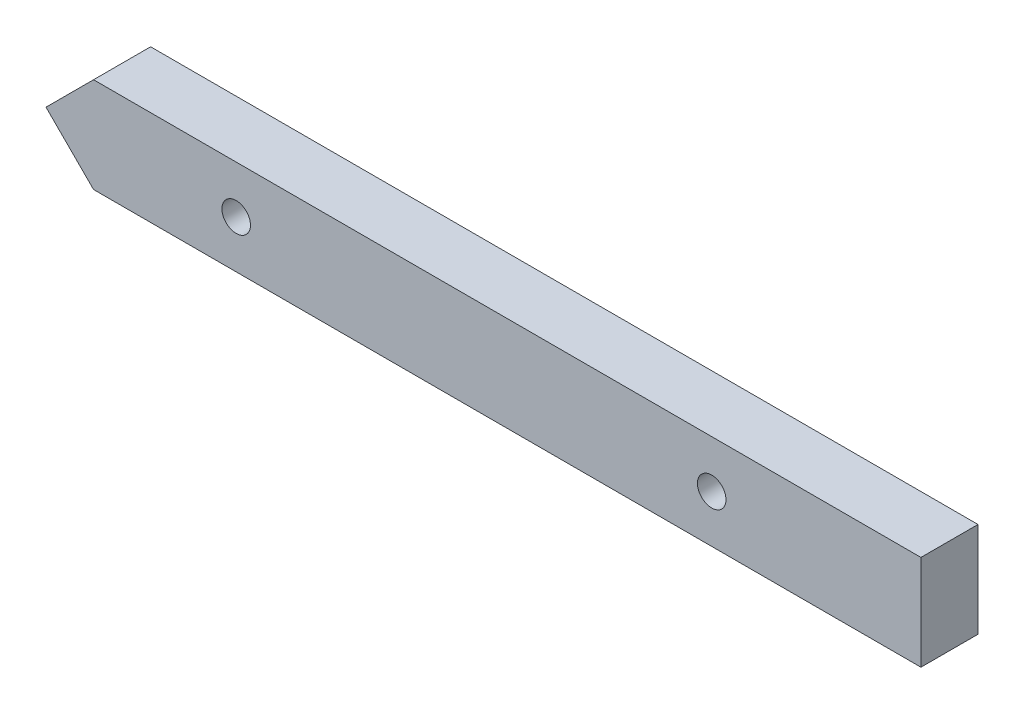
from build123d import *

# Parameters (mm, degrees)
ESQUISSE1_W             = 92
ESQUISSE1_H             = 10
BOSS_EXTRU_1_DEPTH      = 6
ENL_V_MAT_EXTRU_1_DEPTH = 6
ENL_V_MAT_EXTRU_2_DEPTH = 6
ESQUISSE4_R             = 1.5
ENL_V_MAT_EXTRU_3_DEPTH = 6


with BuildPart() as part:
    # Esquisse1 → Boss.-Extru.1 (new body)
    with BuildSketch(Plane.XY):
        Rectangle(ESQUISSE1_W, ESQUISSE1_H)
    extrude(amount=BOSS_EXTRU_1_DEPTH)

    # Esquisse2 → Enlèv. mat.-Extru.1 (cut)
    with BuildSketch(Plane.XY.offset(6)):
        Polygon((-46, -5), (-46, 0), (-41, -5), align=None)
    extrude(amount=-ENL_V_MAT_EXTRU_1_DEPTH, mode=Mode.SUBTRACT)

    # Esquisse3 → Enlèv. mat.-Extru.2 (cut)
    with BuildSketch(Plane.XY.offset(6)):
        Polygon((-46, 0), (-41, 5), (-46, 5), align=None)
    extrude(amount=-ENL_V_MAT_EXTRU_2_DEPTH, mode=Mode.SUBTRACT)

    # Esquisse4 → Enlèv. mat.-Extru.3 (cut)
    with BuildSketch(Plane.XY.offset(6)):
        with Locations((-26, 0)):
            Circle(ESQUISSE4_R)
        with Locations((24, 0)):
            Circle(ESQUISSE4_R)
    extrude(amount=-ENL_V_MAT_EXTRU_3_DEPTH, mode=Mode.SUBTRACT)


solid = part.part
